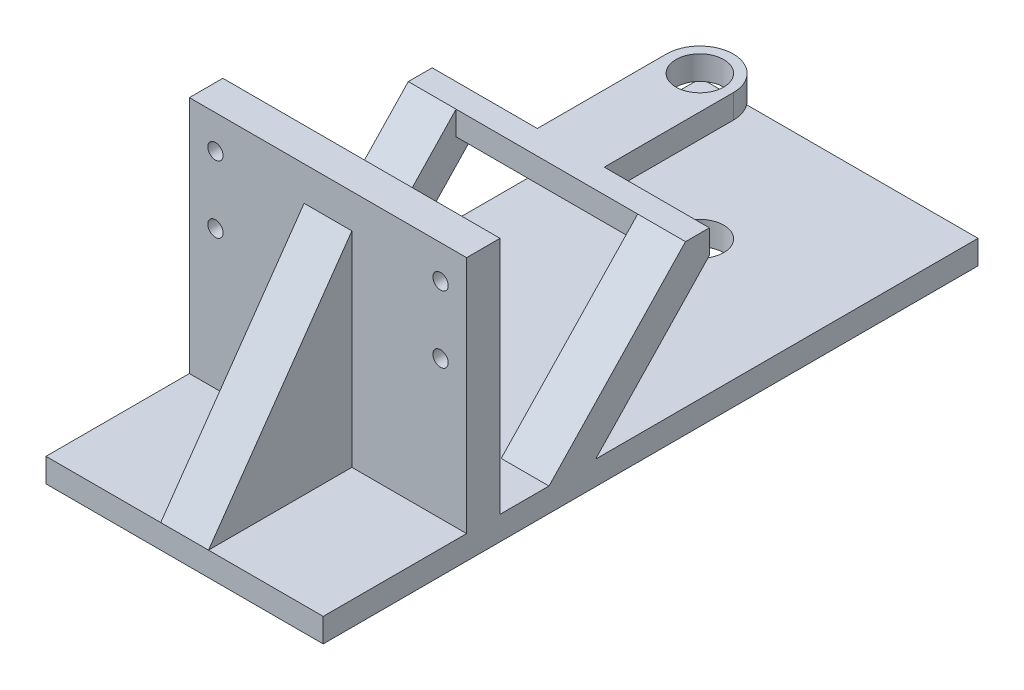
from build123d import *

# Parameters (mm, degrees)
SKETCH1_W            = 73.66
SKETCH1_H            = 69.85
BOSS_EXTRUDE1_DEPTH  = 8.89
SKETCH2_R            = 2.032
CUT_EXTRUDE1_DEPTH   = 8.89
SKETCH3_W            = 73.66
SKETCH3_H            = 6.35
BOSS_EXTRUDE2_DEPTH  = 127
SKETCH4_W            = 73.66
SKETCH4_H            = 6.35
BOSS_EXTRUDE3_DEPTH  = 38.1
BOSS_EXTRUDE4_START  = -36.83
BOSS_EXTRUDE4_DEPTH  = 6.35
SKETCH7_R            = 2.54
SKETCH7_R_2          = 6.35
CUT_EXTRUDE2_DEPTH   = 6.35
BOSS_EXTRUDE15_DEPTH = 12.7
SKETCH23_R           = 6.35
BOSS_EXTRUDE16_DEPTH = 6.35
BOSS_EXTRUDE17_DEPTH = 12.7
SKETCH25_W           = 27.94
SKETCH25_H           = 6.35
BOSS_EXTRUDE18_DEPTH = 6.35


with BuildPart() as part:
    # Sketch1 → Boss-Extrude1 (new body)
    with BuildSketch(Plane.XY):
        Rectangle(SKETCH1_W, SKETCH1_H)
    extrude(amount=BOSS_EXTRUDE1_DEPTH)

    # Sketch2 → Cut-Extrude1 (cut)
    with BuildSketch(Plane(origin=(0, 0, 0), x_dir=(-1, 0, 0), z_dir=(0, 0, -1))):
        with Locations((-29.9085, 26.035)):
            Circle(SKETCH2_R)
        with Locations((-29.9085, 8.255)):
            Circle(SKETCH2_R)
        with Locations((29.9085, 8.255)):
            Circle(SKETCH2_R)
        with Locations((29.9085, 26.035)):
            Circle(SKETCH2_R)
    extrude(amount=-CUT_EXTRUDE1_DEPTH, mode=Mode.SUBTRACT)

    # Sketch3 → Boss-Extrude2 (add)
    with BuildSketch(Plane(origin=(0, 0, 0), x_dir=(-1, 0, 0), z_dir=(0, 0, -1))):
        with Locations((0, -31.75)):
            Rectangle(SKETCH3_W, SKETCH3_H)
    extrude(amount=BOSS_EXTRUDE2_DEPTH)

    # Sketch4 → Boss-Extrude3 (add)
    with BuildSketch(Plane.XY.offset(8.89)):
        with Locations((0, -31.75)):
            Rectangle(SKETCH4_W, SKETCH4_H)
    extrude(amount=BOSS_EXTRUDE3_DEPTH)

    # Sketch5 → Boss-Extrude4 (add, symmetric)
    with BuildSketch(Plane(origin=(36.83, 0, 0), x_dir=(0, 0, -1), z_dir=(1, 0, 0)).offset(BOSS_EXTRUDE4_START)):
        Polygon((-46.99, -28.575), (-8.89, 25.837439057), (-8.89, -28.575), align=None)
    extrude(amount=BOSS_EXTRUDE4_DEPTH, both=True)

    # Sketch7 → Cut-Extrude2 (cut)
    with BuildSketch(Plane(origin=(0, -28.575, 0), x_dir=(1, 0, 0), z_dir=(0, 1, 0))):
        with Locations((0, 26.416)):
            Circle(SKETCH7_R)
        with Locations((0, 89.916)):
            Circle(SKETCH7_R_2)
    extrude(amount=-CUT_EXTRUDE2_DEPTH, mode=Mode.SUBTRACT)

    # Sketch21 → Boss-Extrude15 (add)
    with BuildSketch(Plane.ZY.offset(36.83)):
        Polygon((-25.4, -28.575), (-55.626, 3.175), (-49.276, 3.175), (-49.276, 9.525), (-13.0048, -28.575), align=None)
    extrude(amount=-BOSS_EXTRUDE15_DEPTH)

    # Sketch23 → Boss-Extrude16 (add)
    with BuildSketch(Plane(origin=(0, 3.175, 0), x_dir=(1, 0, 0), z_dir=(0, 1, 0))):
        with BuildLine():
            Line((-36.83, 49.276), (8.89, 49.276))
            Line((8.89, 49.276), (8.89, 89.916))
            ThreePointArc((8.89, 89.916), (0, 98.806), (-8.89, 89.916))
            Line((-8.89, 89.916), (-8.89, 55.626))
            Line((-8.89, 55.626), (-36.83, 55.626))
            Line((-36.83, 55.626), (-36.83, 49.276))
        make_face()
        with Locations((0, 89.916)):
            Circle(SKETCH23_R, mode=Mode.SUBTRACT)
    extrude(amount=BOSS_EXTRUDE16_DEPTH)

    # Sketch24 → Boss-Extrude17 (add)
    with BuildSketch(Plane(origin=(36.83, 0, 0), x_dir=(0, 0, -1), z_dir=(1, 0, 0))):
        Polygon((25.4, -28.575), (55.626, 3.175), (49.276, 3.175), (49.276, 9.525), (13.0048, -28.575), align=None)
    extrude(amount=-BOSS_EXTRUDE17_DEPTH)

    # Sketch25 → Boss-Extrude18 (add)
    with BuildSketch(Plane(origin=(0, 3.175, 0), x_dir=(1, 0, 0), z_dir=(0, 1, 0))):
        with Locations((22.86, 52.451)):
            Rectangle(SKETCH25_W, SKETCH25_H)
    extrude(amount=BOSS_EXTRUDE18_DEPTH)


solid = part.part
